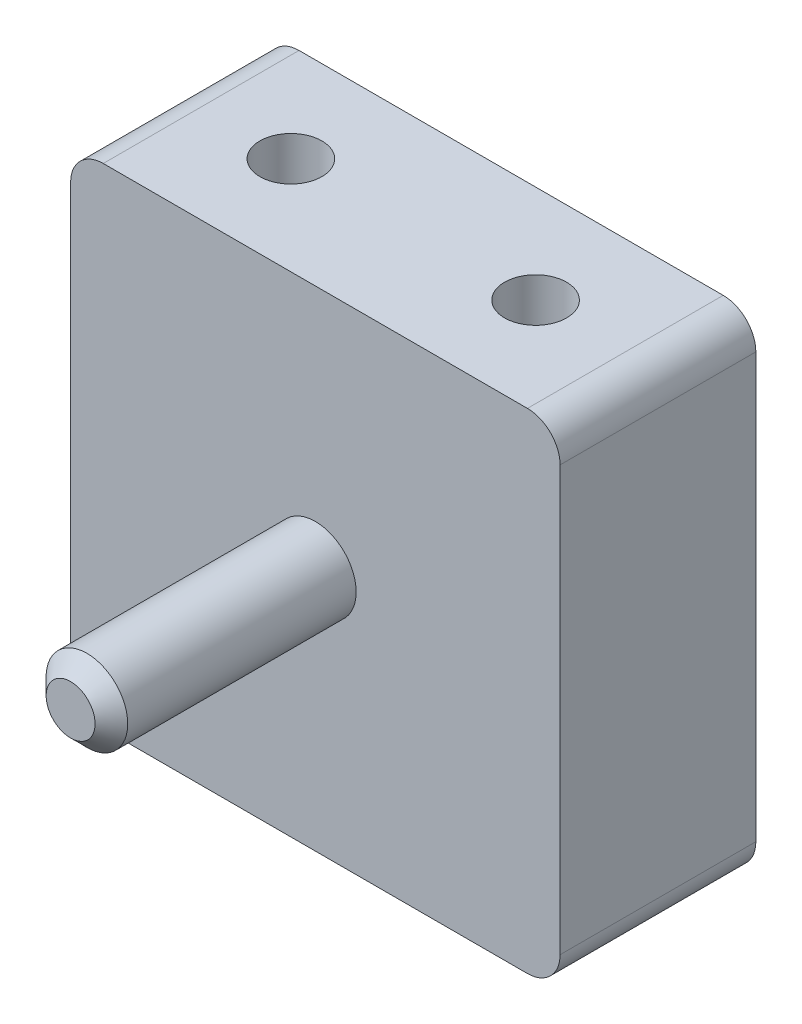
from build123d import *

# Parameters (mm, degrees)
SKETCH1_W           = 38.1
SKETCH1_H           = 38.1
SKETCH1_R           = 1.5875
BOSS_EXTRUDE2_DEPTH = 15.24
SKETCH3_R           = 3.175
BOSS_EXTRUDE3_DEPTH = 19.05
FILLET2_R           = 2.54
CHAMFER1_SIZE       = 1.27
SKETCH4_R           = 2.413
CUT_EXTRUDE2_DEPTH  = 7.62
SKETCH5_R           = 2.413
CUT_EXTRUDE3_DEPTH  = 7.62


with BuildPart() as part:
    # Sketch1 → Boss-Extrude2 (new body)
    with BuildSketch(Plane.XY):
        Rectangle(SKETCH1_W, SKETCH1_H)
        Circle(SKETCH1_R, mode=Mode.SUBTRACT)
    extrude(amount=BOSS_EXTRUDE2_DEPTH)

    # Sketch3 → Boss-Extrude3 (add)
    with BuildSketch(Plane.XY.offset(15.24)):
        Circle(SKETCH3_R)
    extrude(amount=BOSS_EXTRUDE3_DEPTH)

    # Fillet2
    fillet2_edges = [part.edges().sort_by_distance(p)[0] for p in [
        (-19.05, 19.05, 7.62),
        (19.05, 19.05, 7.62),
        (19.05, -19.05, 7.62),
        (-19.05, -19.05, 7.62),
    ]]
    fillet(fillet2_edges, radius=FILLET2_R)

    # Chamfer1
    chamfer1_edges = [part.edges().sort_by_distance(p)[0] for p in [
        (-3.175, 0, 34.29),
    ]]
    chamfer(chamfer1_edges, length=CHAMFER1_SIZE)

    # Sketch4 → Cut-Extrude2 (cut)
    with BuildSketch(Plane.XZ.offset(19.05)):
        with Locations((-9.525, 7.62)):
            Circle(SKETCH4_R)
        with Locations((9.525, 7.62)):
            Circle(SKETCH4_R)
    extrude(amount=-CUT_EXTRUDE2_DEPTH, mode=Mode.SUBTRACT)

    # Sketch5 → Cut-Extrude3 (cut)
    with BuildSketch(Plane(origin=(0, 19.05, 0), x_dir=(1, 0, 0), z_dir=(0, 1, 0))):
        with Locations((9.525, -7.62)):
            Circle(SKETCH5_R)
        with Locations((-9.525, -7.62)):
            Circle(SKETCH5_R)
    extrude(amount=-CUT_EXTRUDE3_DEPTH, mode=Mode.SUBTRACT)


solid = part.part
